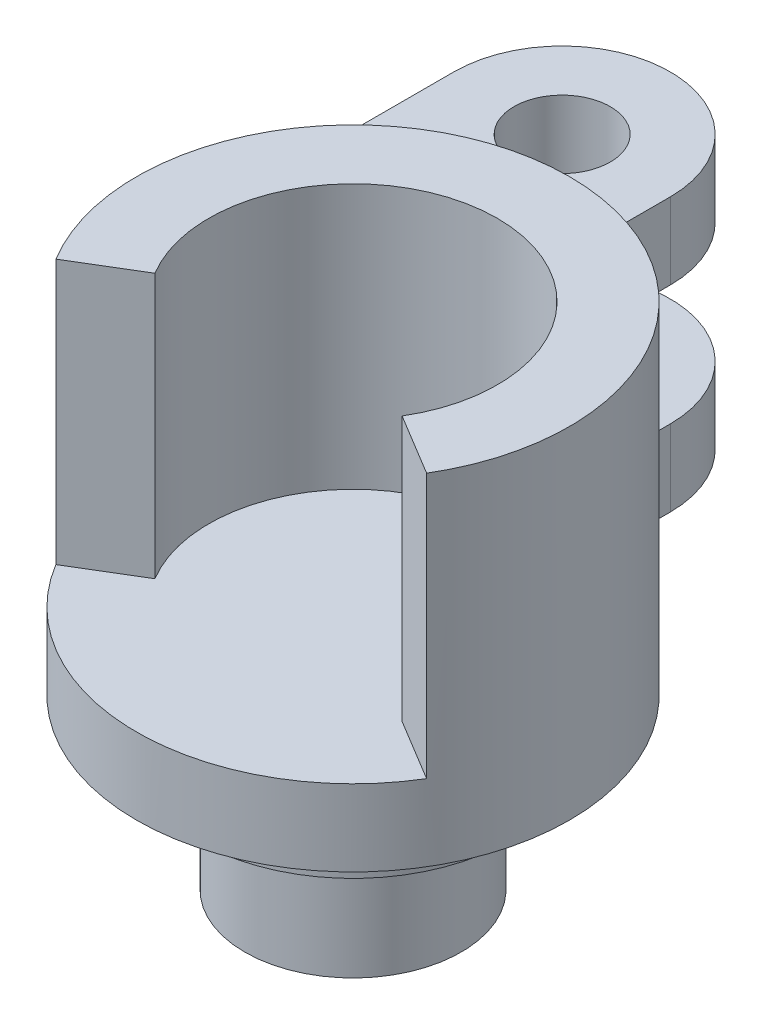
from build123d import *

# Parameters (mm, degrees)
SKETCH1_R           = 9
BOSS_EXTRUDE1_DEPTH = 3.175
BOSS_EXTRUDE2_DEPTH = 11
SKETCH3_R           = 6.5
BOSS_EXTRUDE3_DEPTH = 2
SKETCH4_R           = 4.5
BOSS_EXTRUDE4_DEPTH = 5
BOSS_EXTRUDE5_DEPTH = 3.175
BOSS_EXTRUDE7_DEPTH = 3.175
SKETCH8_R           = 2
CUT_EXTRUDE1_DEPTH  = 11.35


with BuildPart() as part:
    # Sketch1 → Boss-Extrude1 (new body)
    with BuildSketch(Plane(origin=(0, 0, 0), x_dir=(1, 0, 0), z_dir=(0, 1, 0))):
        Circle(SKETCH1_R)
    extrude(amount=BOSS_EXTRUDE1_DEPTH)

    # Sketch2 → Boss-Extrude2 (add)
    with BuildSketch(Plane(origin=(0, 3.175, 0), x_dir=(1, 0, 0), z_dir=(0, 1, 0))):
        with BuildLine():
            Line((-7.707704384, -4.646643211), (-5.138469589, -3.097762141))
            ThreePointArc((-5.138469589, -3.097762141), (0, 6), (5.138469589, -3.097762141))
            Line((5.138469589, -3.097762141), (7.707704384, -4.646643211))
            ThreePointArc((7.707704384, -4.646643211), (0, 9), (-7.707704384, -4.646643211))
        make_face()
    extrude(amount=BOSS_EXTRUDE2_DEPTH)

    # Sketch3 → Boss-Extrude3 (add)
    with BuildSketch(Plane.XZ):
        Circle(SKETCH3_R)
    extrude(amount=BOSS_EXTRUDE3_DEPTH)

    # Sketch4 → Boss-Extrude4 (add)
    with BuildSketch(Plane.XZ.offset(2)):
        Circle(SKETCH4_R)
    extrude(amount=BOSS_EXTRUDE4_DEPTH)

    # Sketch6 → Boss-Extrude5 (add)
    with BuildSketch(Plane(origin=(0, 0, 0), x_dir=(1, 0, 0), z_dir=(0, 1, 0))):
        with BuildLine():
            Line((-9, 0), (-9, 13.194197425))
            ThreePointArc((-9, 13.194197425), (-4.5, 17.694197425), (0, 13.194197425))
            Line((0, 13.194197425), (0, 9))
            ThreePointArc((0, 9), (-6.363961031, 6.363961031), (-9, 0))
        make_face()
    extrude(amount=BOSS_EXTRUDE5_DEPTH)

    # Sketch7 → Boss-Extrude7 (add)
    with BuildSketch(Plane(origin=(0, 8.174999906, 0), x_dir=(1, 0, 0), z_dir=(0, 1, 0))):
        with BuildLine():
            Line((0, 9), (0, 13.194197425))
            ThreePointArc((0, 13.194197425), (-4.5, 17.694197425), (-9, 13.194197425))
            Line((-9, 13.194197425), (-9, 0))
            ThreePointArc((-9, 0), (-6.363961031, 6.363961031), (0, 9))
        make_face()
    extrude(amount=BOSS_EXTRUDE7_DEPTH)

    # Sketch8 → Cut-Extrude1 (cut)
    with BuildSketch(Plane(origin=(0, 11.349999906, 0), x_dir=(1, 0, 0), z_dir=(0, 1, 0))):
        with Locations((-4.5, 13.194197425)):
            Circle(SKETCH8_R)
    extrude(amount=-CUT_EXTRUDE1_DEPTH, mode=Mode.SUBTRACT)


solid = part.part
